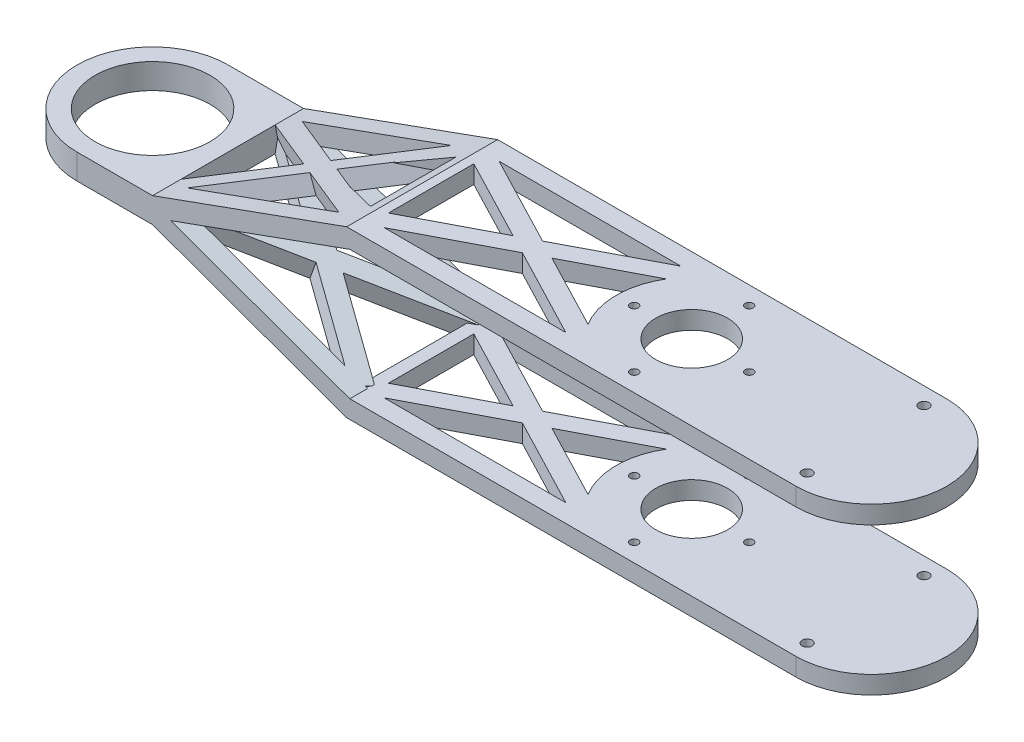
from build123d import *

# Parameters (mm, degrees)
SKETCH_1_R               = 21
SKETCH_1_R_2             = 16
EXTRUDE_1_DEPTH          = 46
SKETCH_1_R_3             = 10
EXTRUDE_1_2_DEPTH        = 46
SKETCH_2_W               = 150
SKETCH_2_H               = 5
EXTRUDE_3_DEPTH          = 5
SKETCH_3_W               = 150
SKETCH_3_H               = 5
EXTRUDE_4_DEPTH          = 5
EXTRUDE_5_DEPTH          = 5
SKETCH_6_W               = 169.409921662
SKETCH_6_H               = 36
CUT_EXTRUDE_1_DEPTH      = 42
CUT_EXTRUDE_4_REACH      = 155.15
EXTRUDE_7_DEPTH          = 5
EXTRUDE_8_REACH          = 155.15
EXTRUDE_8_END_RADIUS     = 21
SKETCH_10_W              = 21
SKETCH_10_H              = 7
SKETCH_11_W              = 54.75
SKETCH_11_H              = 32.4550301
CUT_EXTRUDE_5_DEPTH      = 5
EXTRUDE_15_DEPTH         = 5
SKETCH_13_R              = 1.125
CUT_EXTRUDE_6_DEPTH      = 150.607304507
CUT_EXTRUDE_6_DEPTH_BACK = 150.607304507
SKETCH_14_R              = 1.4
CUT_EXTRUDE_7_DEPTH      = 150.607304507
CUT_EXTRUDE_7_DEPTH_BACK = 150.607304507


with BuildPart() as part:
    # 스케치1 → 보스-돌출1 (new body)
    with BuildSketch(Plane(origin=(0, 0, 0), x_dir=(1, 0, 0), z_dir=(0, 1, 0))):
        with Locations(Location((-81.089427727, -5.294054995, 0), (0, 0, 270))):
            Circle(SKETCH_1_R)
        with Locations(Location((-81.089427727, -5.294054995, 0), (0, 0, 270))):
            Circle(SKETCH_1_R_2, mode=Mode.SUBTRACT)
    extrude(amount=EXTRUDE_1_DEPTH)



with BuildPart() as body_2:
    # 스케치1 → Extrude 1 2 (new body)
    with BuildSketch(Plane(origin=(0, 0, 0), x_dir=(1, 0, 0), z_dir=(0, 1, 0))):
        with BuildLine():
            Line((68.910572273, 15.705945005), (118.910572273, 15.705945005))
            ThreePointArc((118.910572273, 15.705945005), (139.910572273, -5.294054995), (118.910572273, -26.294054995))
            Line((118.910572273, -26.294054995), (68.910572273, -26.294054995))
            ThreePointArc((68.910572273, -26.294054995), (47.910572273, -5.294054995), (68.910572273, 15.705945005))
        make_face()
        with Locations(Location((68.910572273, -5.294054995, 0), (0, 0, 270))):
            Circle(SKETCH_1_R_3, mode=Mode.SUBTRACT)
    extrude(amount=EXTRUDE_1_2_DEPTH)


with BuildPart() as part_1:
    add(part.part)

    add(body_2.part)  # 보스-돌출3 merges body 2
    # 스케치2 → 보스-돌출3 (add)
    with BuildSketch(Plane(origin=(0, 46, 0), x_dir=(1, 0, 0), z_dir=(0, 1, 0))):
        with Locations((-6.089427727, -23.794054995)):
            Rectangle(SKETCH_2_W, SKETCH_2_H)
        with Locations((-6.089427727, 13.205945005)):
            Rectangle(SKETCH_2_W, SKETCH_2_H)
    extrude(amount=-EXTRUDE_3_DEPTH)

    # 스케치3 → 보스-돌출4 (add)
    with BuildSketch(Plane.XZ):
        with Locations((-6.089427727, -13.205945005)):
            Rectangle(SKETCH_3_W, SKETCH_3_H)
        with Locations((-6.089427727, 23.794054995)):
            Rectangle(SKETCH_3_W, SKETCH_3_H)
    extrude(amount=-EXTRUDE_4_DEPTH)

    # 스케치4 → 보스-돌출5 (add)
    with BuildSketch(Plane.XZ):
        Polygon((-36.788692473, 8.113223678), (-7.244877213, 23.511020598), (-6.089427727, 21.294054995), (-4.933978242, 23.511020598), (24.609837018, 8.113223678), (54.153652279, 23.511020598), (56.46455125, 19.077089392), (30.018987378, 5.294054995), (56.46455125, -8.488979402), (54.153652279, -12.922910608), (24.609837018, 2.474886312), (-4.933978242, -12.922910608), (-7.244877213, -12.922910608), (-36.788692473, 2.474886312), (-66.332507733, -12.922910608), (-68.643406704, -8.488979402), (-42.197842833, 5.294054995), (-68.643406704, 19.077089392), (-66.332507733, 23.511020598), align=None)
        Polygon((-31.379542113, 5.294054995), (-8.589427727, -6.583813521), (-8.589427727, 17.17192351), align=None, mode=Mode.SUBTRACT)
        Polygon((-3.589427727, -6.583813521), (19.200686659, 5.294054995), (-3.589427727, 17.17192351), align=None, mode=Mode.SUBTRACT)
    extrude_5 = extrude(amount=-EXTRUDE_5_DEPTH)

    # 스케치6 → 컷-돌출1 (cut)
    with BuildSketch(Plane(origin=(0, 0, -15.705945005), x_dir=(-1, 0, 0), z_dir=(0, 0, -1))):
        with Locations((-75.35345041, 23)):
            Rectangle(SKETCH_6_W, SKETCH_6_H)
    extrude(amount=-CUT_EXTRUDE_1_DEPTH, mode=Mode.SUBTRACT)

    # 대칭 복사1: 보스-돌출5 across plane
    add(extrude_5.mirror(Plane.ZX.offset(23)))

    # 컷-돌출4: up to this face of the body (flat: up to its plane)
    cut_extrude_4_end = Plane(part_1.part.faces().sort_by_distance((18.910572273, 43.5, 26.294054995))[0])
    # 스케치7 → 컷-돌출4 (cut, up to the picked face)
    with BuildSketch(Plane(origin=(0, 0, -15.705945005), x_dir=(-1, 0, 0), z_dir=(0, 0, -1)), mode=Mode.PRIVATE) as cut_extrude_4_sk1:
        Polygon((6.089427727, 0), (60.089427727, 19.5), (108.089427727, 19.5), (108.089427727, 26.5), (60.089427727, 26.5), (6.089427727, 46), (127.814090618, 46), (127.814090618, 0), align=None)
    cut_extrude_4_tool1 = split(extrude(cut_extrude_4_sk1.sketch, amount=-CUT_EXTRUDE_4_REACH, mode=Mode.PRIVATE), bisect_by=cut_extrude_4_end, keep=Keep.BOTH, mode=Mode.PRIVATE)
    add(cut_extrude_4_tool1.solids().sort_by(Axis((-33.531395, 8.526091, -15.705945), (0, 0, 1)))[0], mode=Mode.SUBTRACT)


with BuildPart() as cut_extrude_4_piece_1:
    # of the separate pieces the step leaves, piece 1, a body of its own (cut_extrude_4_pieces)
    add(part_1.part.solids().sort_by_distance((-6.089427727, 0, -15.705945005))[0])



with BuildPart() as cut_extrude_4_piece_2:
    # of the separate pieces the step leaves, piece 2, a body of its own (cut_extrude_4_pieces)
    add(part_1.part.solids().sort_by_distance((118.910572273, 41, 26.294054995))[0])


with BuildPart() as cut_extrude_4_piece_3:
    # of the separate pieces the step leaves, piece 3, a body of its own (cut_extrude_4_pieces)
    add(part_1.part.solids().sort_by_distance((-81.089427727, 19.5, 26.294054995))[0])


with BuildPart() as cut_extrude_4_piece_1_1:
    add(cut_extrude_4_piece_1.part)

    add(cut_extrude_4_piece_2.part)  # 보스-돌출7 merges 컷-돌출4 piece 2

    add(cut_extrude_4_piece_3.part)  # 보스-돌출7 merges 컷-돌출4 piece 3
    # 스케치9 → 보스-돌출7 (add)
    with BuildSketch(Plane(origin=(0, 0, -15.705945005), x_dir=(-1, 0, 0), z_dir=(0, 0, -1))):
        Polygon((4.391205408, 41.297230502), (55.060459105, 23), (4.391205408, 4.702769498), (6.089427727, 0), (69.781735419, 23), (6.089427727, 46), align=None)
    extrude_7 = extrude(amount=-EXTRUDE_7_DEPTH)

    # 보스-돌출8: up to this cylinder (the profile starts outside it)
    extrude_8_end = Plane(origin=(-81.089427727, 23, 5.294054995), z_dir=(0, -1, 0)) * Cylinder(EXTRUDE_8_END_RADIUS, 353.3, mode=Mode.PRIVATE)
    # 스케치10 → 보스-돌출8 (add, up to the surface)
    with BuildSketch(Plane(origin=(0, 0, -15.705945005), x_dir=(-1, 0, 0), z_dir=(0, 0, -1)), mode=Mode.PRIVATE) as extrude_8_sk1:
        with Locations((70.589427727, 23)):
            Rectangle(SKETCH_10_W, SKETCH_10_H)
    extrude_8_tool1 = extrude(extrude_8_sk1.sketch, amount=-EXTRUDE_8_REACH, mode=Mode.PRIVATE) - extrude_8_end
    extrude_8 = extrude_8_tool1.solids().sort_by_distance((-70.589428, 23, -15.705945))[0]
    add(extrude_8)

    # 대칭 복사2: 보스-돌출7, 보스-돌출8 across plane
    add(extrude_7.mirror(Plane(origin=(0, 0, 5.294054995), x_dir=(1, 0, 0), z_dir=(0, 0, -1))))
    add(extrude_8.mirror(Plane(origin=(0, 0, 5.294054995), x_dir=(1, 0, 0), z_dir=(0, 0, -1))))

    # 스케치11 → 컷-돌출5 (cut)
    with BuildSketch(Plane(origin=(-0.702466407, -1.945291588, 0), x_dir=(0.9405538996916954, -0.3396444637775568, 0), z_dir=(-0.3396444637775568, -0.9405538996916956, 0))):
        with Locations((-35.765412623, 5.066539945)):
            Rectangle(SKETCH_11_W, SKETCH_11_H)
    extrude(amount=-CUT_EXTRUDE_5_DEPTH, mode=Mode.SUBTRACT)

    # 스케치12 → 보스-돌출15 (add)
    with BuildSketch(Plane(origin=(-0.702466407, -1.945291588, 0), x_dir=(0.9405538996916956, -0.33964446377755675, 0), z_dir=(-0.33964446377755675, -0.9405538996916956, 0))):
        Polygon((-31.030335125, 5.165890673), (-6.246195793, -9.525798606), (-8.795823184, -13.826891509), (-35.96762349, 2.280169619), (-64.18375705, -14.211451822), (-66.706787961, -9.894703622), (-40.887006083, 5.196310444), (-66.473080759, 20.363375718), (-63.923453368, 24.664468621), (-35.949717718, 8.082031497), (-8.84109266, 23.926342034), (-6.318061748, 19.609593834), align=None)
    extrude_15 = extrude(amount=-EXTRUDE_15_DEPTH)

    # 대칭 복사3: 보스-돌출15 across plane
    add(extrude_15.mirror(Plane.ZX.offset(23)))

    # 스케치13 → 컷-돌출6 (cut, two sides)
    with BuildSketch(Plane(origin=(0, 46, 0), x_dir=(1, 0, 0), z_dir=(0, 1, 0))) as cut_extrude_6_sk:
        with Locations(Location((84.910572273, -5.294054995, 0), (0, 0, 270))):
            Circle(SKETCH_13_R)
        with Locations(Location((52.910572273, -5.294054995, 0), (0, 0, 270))):
            Circle(SKETCH_13_R)
        with Locations(Location((68.910572273, -21.294054995, 0), (0, 0, 270))):
            Circle(SKETCH_13_R)
        with Locations(Location((68.910572273, 10.705945005, 0), (0, 0, 270))):
            Circle(SKETCH_13_R)
    extrude(amount=CUT_EXTRUDE_6_DEPTH, mode=Mode.SUBTRACT)
    extrude(cut_extrude_6_sk.sketch, amount=-CUT_EXTRUDE_6_DEPTH_BACK, mode=Mode.SUBTRACT)

    # 스케치14 → 컷-돌출7 (cut, two sides)
    with BuildSketch(Plane(origin=(0, 46, 0), x_dir=(1, 0, 0), z_dir=(0, 1, 0))) as cut_extrude_7_sk:
        with Locations(Location((117.277150097, 10.955945005, 0), (0, 0, 270))):
            Circle(SKETCH_14_R)
        with Locations(Location((117.277150097, -21.544054995, 0), (0, 0, 270))):
            Circle(SKETCH_14_R)
    extrude(amount=CUT_EXTRUDE_7_DEPTH, mode=Mode.SUBTRACT)
    extrude(cut_extrude_7_sk.sketch, amount=-CUT_EXTRUDE_7_DEPTH_BACK, mode=Mode.SUBTRACT)


solid = cut_extrude_4_piece_1_1.part
